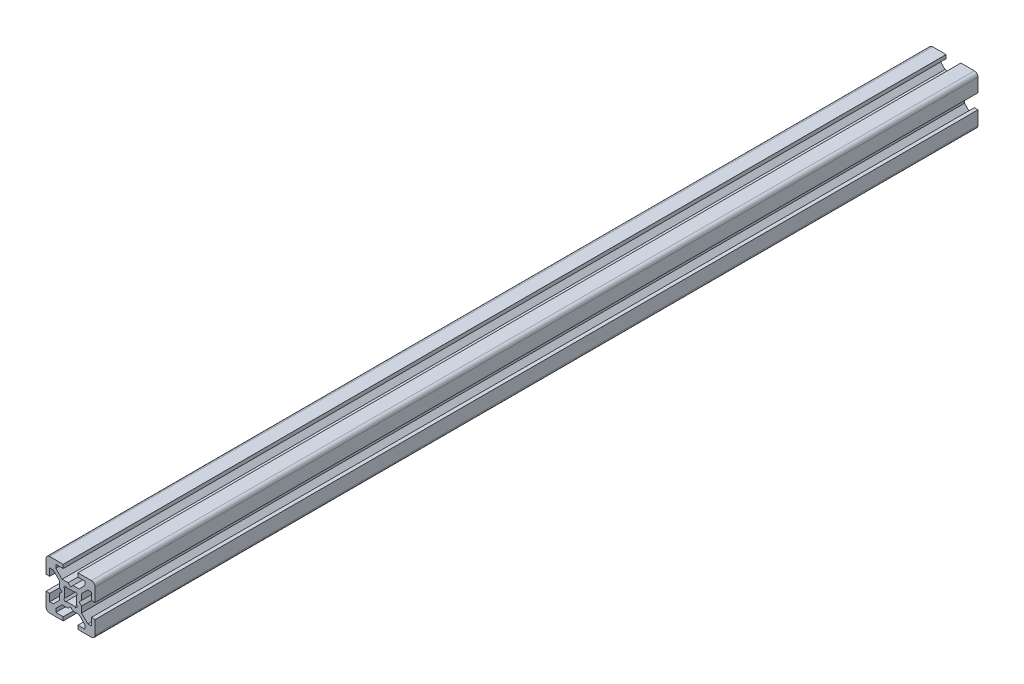
from build123d import *

# Parameters (mm, degrees)
BOSS_EXTRUDE1_DEPTH = 360
FILLET1_R           = 1.5


with BuildPart() as part:
    # Sketch1 → Boss-Extrude1 (new body)
    with BuildSketch(Plane.XY):
        Polygon((0, 3.5), (1, 4.5), (3.439339828, 4.5), (6, 7.060660172), (6, 8.5), (3, 8.5), (3, 10), (10, 10), (10, 3), (8.5, 3), (8.5, 6), (7.060660172, 6), (4.5, 3.439339828), (4.5, 1), (3.5, 0), (4.5, -1), (4.5, -3.439339828), (7.060660172, -6), (8.5, -6), (8.5, -3), (10, -3), (10, -10), (3, -10), (3, -8.5), (6, -8.5), (6, -7.060660172), (3.439339828, -4.5), (1, -4.5), (0, -3.5), (-1, -4.5), (-3.439339828, -4.5), (-6, -7.060660172), (-6, -8.5), (-3, -8.5), (-3, -10), (-10, -10), (-10, -3), (-8.5, -3), (-8.5, -6), (-7.060660172, -6), (-4.5, -3.439339828), (-4.5, -1), (-3.5, 0), (-4.5, 1), (-4.5, 3.439339828), (-7.060660172, 6), (-8.5, 6), (-8.5, 3), (-10, 3), (-10, 10), (-3, 10), (-3, 8.5), (-6, 8.5), (-6, 7.060660172), (-3.439339828, 4.5), (-1, 4.5), align=None)
        Polygon((-1.792893219, 2.5), (1.792893219, 2.5), (2.121320344, 2.828427125), (2.828427125, 2.121320344), (2.5, 1.792893219), (2.5, -1.792893219), (2.828427125, -2.121320344), (2.121320344, -2.828427125), (1.792893219, -2.5), (-1.792893219, -2.5), (-2.121320344, -2.828427125), (-2.828427125, -2.121320344), (-2.5, -1.792893219), (-2.5, 1.792893219), (-2.828427125, 2.121320344), (-2.121320344, 2.828427125), align=None, mode=Mode.SUBTRACT)
    extrude(amount=BOSS_EXTRUDE1_DEPTH)

    # Fillet1
    fillet1_edges = [part.edges().sort_by_distance(p)[0] for p in [
        (10, 10, 180),
        (10, -10, 180),
        (-10, -10, 180),
        (-10, 10, 180),
    ]]
    fillet(fillet1_edges, radius=FILLET1_R)


solid = part.part
